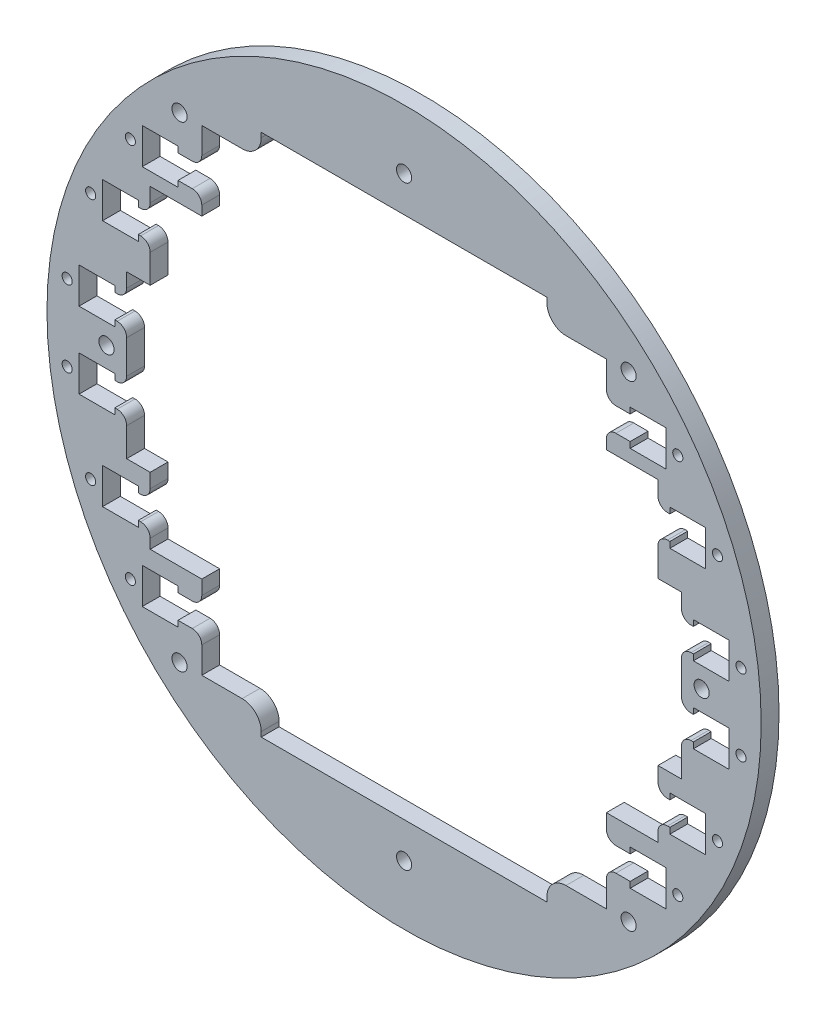
from build123d import *

# Parameters (mm, degrees)
SKETCH1_R                  = 95.25
BOSS_EXTRUDE1_DEPTH        = 4.7625
CUT_EXTRUDE1_DEPTH         = 5.7625
SKETCH12_W                 = 136.486274728
SKETCH12_H                 = 6.35
SKETCH12_W_2               = 157.666649448
SKETCH12_W_3               = 170.194766776
CUT_EXTRUDE2_DEPTH         = 5.7625
CUT_EXTRUDE3_DEPTH         = 5.7625
F_10_32_TAPPED_HOLE1_D     = 4.0386
F_10_32_TAPPED_HOLE1_DEPTH = 11.938
SKETCH14_W                 = 76.2
SKETCH14_H                 = 139.7
CUT_EXTRUDE4_DEPTH         = 5.7625
FILLET1_R                  = 5.08
FILLET3_R                  = 2.54
F_6_32_TAPPED_HOLE1_D      = 2.7051
F_6_32_TAPPED_HOLE1_DEPTH  = 9.398
F_10_32_TAPPED_HOLE3_D     = 4.0386


with BuildPart() as part:
    # Sketch1 → Boss-Extrude1 (new body)
    with BuildSketch(Plane.XY):
        Circle(SKETCH1_R)
    extrude(amount=BOSS_EXTRUDE1_DEPTH)

    # Sketch11 → Cut-Extrude1 (cut, through all)
    with BuildSketch(Plane.XY.offset(4.7625)):
        Polygon((-69.830637364, 55.5625), (-69.830637364, 46.0375), (-60.305637364, 46.0375), (-60.305637364, 47.625), (-68.243137364, 47.625), (-68.243137364, 53.975), (-60.305637364, 53.975), (-60.305637364, 55.5625), align=None)
        Polygon((-86.684883388, 14.9225), (-86.684883388, 5.3975), (-77.159883388, 5.3975), (-77.159883388, 6.985), (-85.097383388, 6.985), (-85.097383388, 13.335), (-77.159883388, 13.335), (-77.159883388, 14.9225), align=None)
        Polygon((-80.420824724, 37.7825), (-80.420824724, 28.2575), (-70.895824724, 28.2575), (-70.895824724, 29.845), (-78.833324724, 29.845), (-78.833324724, 36.195), (-70.895824724, 36.195), (-70.895824724, 37.7825), align=None)
        Polygon((-77.159883388, -13.335), (-77.159883388, -14.9225), (-86.684883388, -14.9225), (-86.684883388, -5.3975), (-77.159883388, -5.3975), (-77.159883388, -6.985), (-85.097383388, -6.985), (-85.097383388, -13.335), align=None)
        Polygon((-80.420824724, -28.2575), (-70.895824724, -28.2575), (-70.895824724, -29.845), (-78.833324724, -29.845), (-78.833324724, -36.195), (-70.895824724, -36.195), (-70.895824724, -37.7825), (-80.420824724, -37.7825), align=None)
        Polygon((-60.305637364, -46.0375), (-60.305637364, -47.625), (-68.243137364, -47.625), (-68.243137364, -53.975), (-60.305637364, -53.975), (-60.305637364, -55.5625), (-69.830637364, -55.5625), (-69.830637364, -46.0375), align=None)
        Polygon((60.305637364, -53.975), (60.305637364, -55.5625), (69.830637364, -55.5625), (69.830637364, -46.0375), (60.305637364, -46.0375), (60.305637364, -47.625), (68.243137364, -47.625), (68.243137364, -53.975), align=None)
        Polygon((70.895824724, -36.195), (70.895824724, -37.7825), (80.420824724, -37.7825), (80.420824724, -28.2575), (70.895824724, -28.2575), (70.895824724, -29.845), (78.833324724, -29.845), (78.833324724, -36.195), align=None)
        Polygon((86.684883388, -5.3975), (77.159883388, -5.3975), (77.159883388, -6.985), (85.097383388, -6.985), (85.097383388, -13.335), (77.159883388, -13.335), (77.159883388, -14.9225), (86.684883388, -14.9225), align=None)
        Polygon((70.895824724, 37.7825), (80.420824724, 37.7825), (80.420824724, 28.2575), (70.895824724, 28.2575), (70.895824724, 29.845), (78.833324724, 29.845), (78.833324724, 36.195), (70.895824724, 36.195), align=None)
        Polygon((77.159883388, 14.9225), (86.684883388, 14.9225), (86.684883388, 5.3975), (77.159883388, 5.3975), (77.159883388, 6.985), (85.097383388, 6.985), (85.097383388, 13.335), (77.159883388, 13.335), align=None)
        Polygon((60.305637364, 55.5625), (69.830637364, 55.5625), (69.830637364, 46.0375), (60.305637364, 46.0375), (60.305637364, 47.625), (68.243137364, 47.625), (68.243137364, 53.975), (60.305637364, 53.975), align=None)
    extrude(amount=-CUT_EXTRUDE1_DEPTH, mode=Mode.SUBTRACT)

    # Sketch12 → Cut-Extrude2 (cut, through all)
    with BuildSketch(Plane.XY.offset(4.7625)):
        with Locations((0, 50.8)):
            Rectangle(SKETCH12_W, SKETCH12_H)
        with Locations((0, 33.02)):
            Rectangle(SKETCH12_W_2, SKETCH12_H)
        with Locations((0, 10.16)):
            Rectangle(SKETCH12_W_3, SKETCH12_H)
        with Locations((0, -10.16)):
            Rectangle(SKETCH12_W_3, SKETCH12_H)
        with Locations((0, -33.02)):
            Rectangle(SKETCH12_W_2, SKETCH12_H)
        with Locations((0, -50.8)):
            Rectangle(SKETCH12_W, SKETCH12_H)
    extrude(amount=-CUT_EXTRUDE2_DEPTH, mode=Mode.SUBTRACT)

    # Sketch13 → Cut-Extrude3 (cut, through all)
    with BuildSketch(Plane.XY.offset(4.7625)):
        Polygon((53.955637364, 42.545), (67.720824724, 42.545), (67.720824724, 19.685), (73.984883388, 19.685), (73.984883388, -23.495), (67.720824724, -23.495), (67.720824724, -41.275), (53.955637364, -41.275), (53.955637364, -63.5), (-53.955637364, -63.5), (-53.955637364, -41.275), (-67.720824724, -41.275), (-67.720824724, -23.495), (-73.984883388, -23.495), (-73.984883388, 19.685), (-67.720824724, 19.685), (-67.720824724, 42.545), (-53.955637364, 42.545), (-53.955637364, 63.5), (53.955637364, 63.5), align=None)
    extrude(amount=-CUT_EXTRUDE3_DEPTH, mode=Mode.SUBTRACT)

    # #10-32 Tapped Hole1
    with Locations(Plane.XY.offset(4.7625)):
        with Locations((-59.89185243, 63.5), (59.89185243, 63.5)):
            f_10_32_tapped_hole1 = Hole(F_10_32_TAPPED_HOLE1_D / 2, depth=F_10_32_TAPPED_HOLE1_DEPTH)

    # Mirror1: #10-32 Tapped Hole1 across plane
    add(f_10_32_tapped_hole1.mirror(Plane.ZX), mode=Mode.SUBTRACT)

    # Sketch14 → Cut-Extrude4 (cut, through all)
    with BuildSketch(Plane.XY.offset(4.7625)):
        Rectangle(SKETCH14_W, SKETCH14_H)
    extrude(amount=-CUT_EXTRUDE4_DEPTH, mode=Mode.SUBTRACT)

    # Fillet1
    fillet1_edges = [part.edges().sort_by_distance(p)[0] for p in [
        (38.1, 63.5, 2.38125),
        (-38.1, 63.5, 2.38125),
        (-38.1, -63.5, 2.38125),
        (38.1, -63.5, 2.38125),
    ]]
    fillet(fillet1_edges, radius=FILLET1_R)

    # Fillet3
    fillet3_edges = [part.edges().sort_by_distance(p)[0] for p in [
        (-53.955637364, -47.625, 2.38125),
        (53.955637364, -47.625, 2.38125),
        (-67.720824724, -29.845, 2.38125),
        (67.720824724, -29.845, 2.38125),
        (-73.984883388, -13.335, 2.38125),
        (73.984883388, -13.335, 2.38125),
        (-67.720824724, 36.195, 2.38125),
        (67.720824724, 36.195, 2.38125),
        (53.955637364, 53.975, 2.38125),
        (-53.955637364, 53.975, 2.38125),
        (53.955637364, 47.625, 2.38125),
        (-67.720824724, 29.845, 2.38125),
        (73.984883388, 6.985, 2.38125),
        (73.984883388, 13.335, 2.38125),
        (-73.984883388, 6.985, 2.38125),
        (-73.984883388, -6.985, 2.38125),
        (-73.984883388, 13.335, 2.38125),
        (-67.720824724, -36.195, 2.38125),
        (53.955637364, -53.975, 2.38125),
        (67.720824724, 29.845, 2.38125),
        (73.984883388, -6.985, 2.38125),
        (67.720824724, -36.195, 2.38125),
        (-53.955637364, -53.975, 2.38125),
        (-53.955637364, 47.625, 2.38125),
    ]]
    fillet(fillet3_edges, radius=FILLET3_R)

    # #6-32 Tapped Hole1
    with Locations(Plane.XY.offset(4.7625)):
        with Locations((-73.005637364, 50.8), (-83.595824724, 33.02), (-89.859883388, 10.16), (-89.859883388, -10.16), (-83.595824724, -33.02), (-73.005637364, -50.8), (73.005637364, -50.8), (83.595824724, -33.02), (89.859883388, -10.16), (89.859883388, 10.16), (83.595824724, 33.02), (73.005637364, 50.8)):
            Hole(F_6_32_TAPPED_HOLE1_D / 2, depth=F_6_32_TAPPED_HOLE1_DEPTH)

    # #10-32 Tapped Hole3 (through all)
    with Locations(Plane.XY.offset(4.7625)):
        with Locations((0, 79.375), (-79.375, 0), (0, -79.375), (79.375, 0)):
            Hole(F_10_32_TAPPED_HOLE3_D / 2)


solid = part.part
